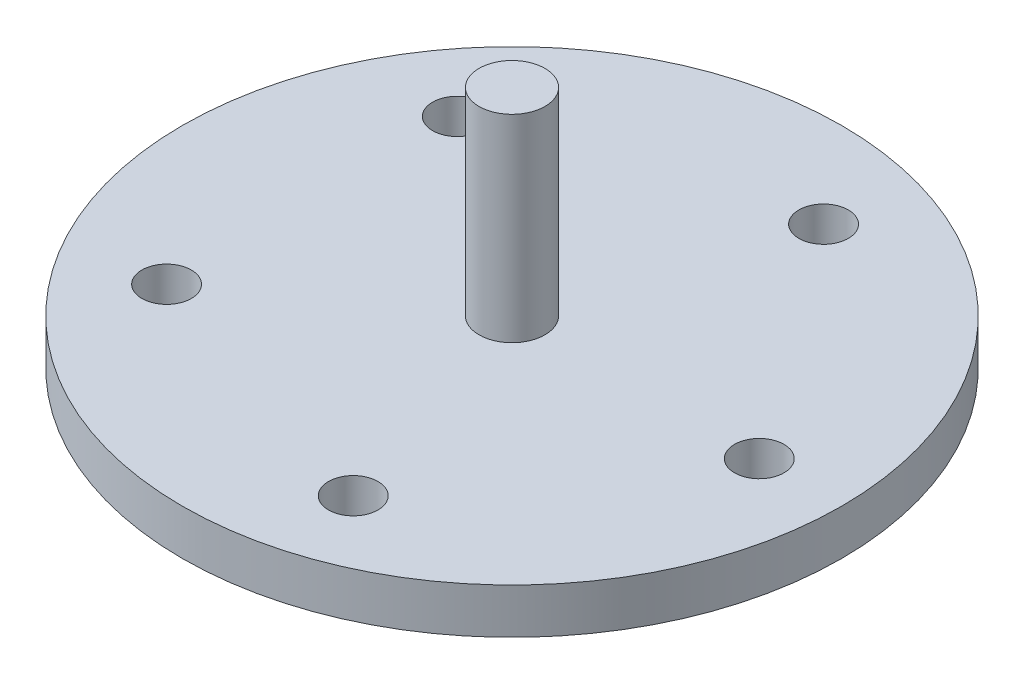
from build123d import *

# Parameters (mm, degrees)
SKETCH1_R           = 40
BOSS_EXTRUDE1_DEPTH = 5.5
SKETCH2_R           = 3
CUT_EXTRUDE1_DEPTH  = 6.5
CIRPATTERN1_COUNT   = 5
SKETCH3_R           = 4
BOSS_EXTRUDE2_DEPTH = 24


with BuildPart() as part:
    # Sketch1 → Boss-Extrude1 (new body)
    with BuildSketch(Plane(origin=(0, 0, 0), x_dir=(1, 0, 0), z_dir=(0, 1, 0))):
        Circle(SKETCH1_R)
    extrude(amount=BOSS_EXTRUDE1_DEPTH)

    # Sketch2 → Cut-Extrude1 (cut, through all)
    with BuildSketch(Plane(origin=(0, 5.5, 0), x_dir=(1, 0, 0), z_dir=(0, 1, 0))):
        with Locations((30, 0)):
            Circle(SKETCH2_R)
    cut_extrude1 = extrude(amount=-CUT_EXTRUDE1_DEPTH, mode=Mode.SUBTRACT)

    # CirPattern1: Cut-Extrude1 ×5 about axis
    cirpattern1_axis = Axis((0, 0, 0), (0, 1, 0))
    for i in range(1, CIRPATTERN1_COUNT):
        add(cut_extrude1.rotate(cirpattern1_axis, i * 360 / CIRPATTERN1_COUNT), mode=Mode.SUBTRACT)

    # Sketch3 → Boss-Extrude2 (add)
    with BuildSketch(Plane(origin=(0, 5.5, 0), x_dir=(1, 0, 0), z_dir=(0, 1, 0))):
        Circle(SKETCH3_R)
    extrude(amount=BOSS_EXTRUDE2_DEPTH)


solid = part.part
